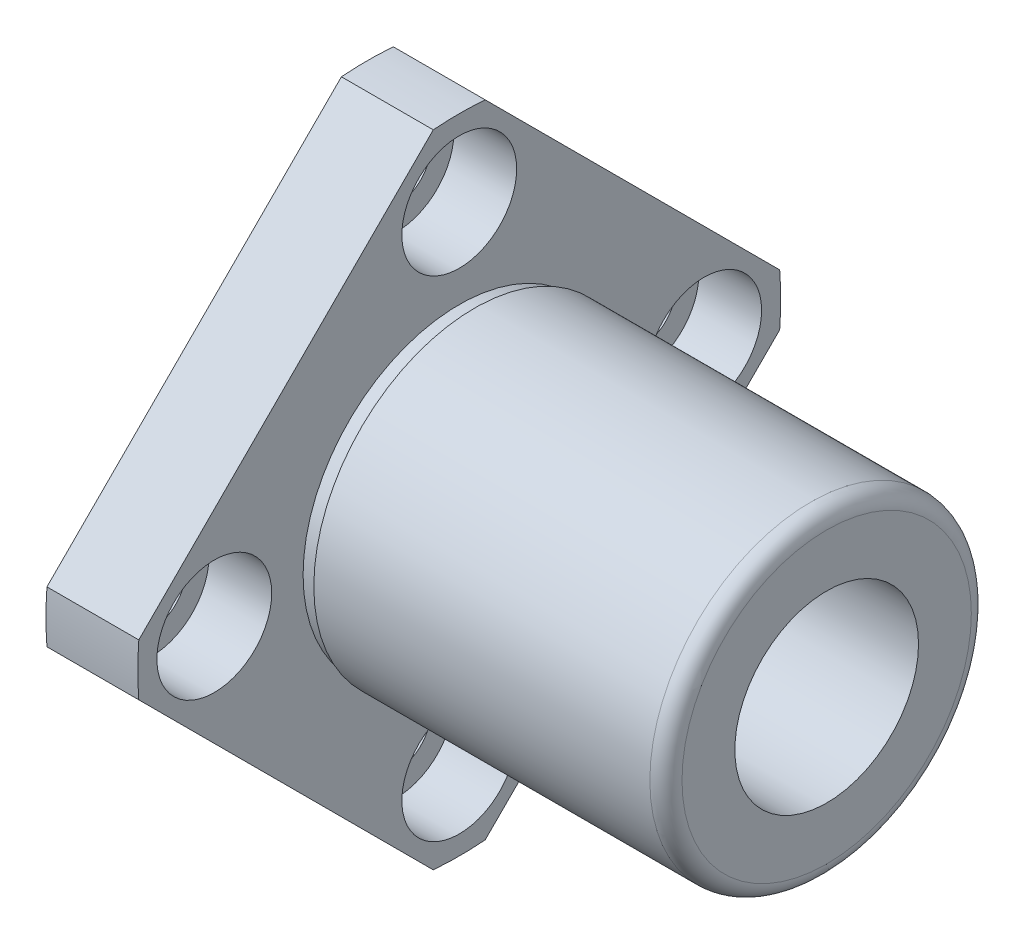
from build123d import *

# Parameters (mm, degrees)
BOSS_EXTRUDE1_DEPTH                              = 6
CBORE_FOR_M4_HEX_HEAD_MACHINE_SCREW1_D           = 4.5
CBORE_FOR_M4_HEX_HEAD_MACHINE_SCREW1_DEPTH       = 6
CBORE_FOR_M4_HEX_HEAD_MACHINE_SCREW1_CBORE_D     = 7.5
CBORE_FOR_M4_HEX_HEAD_MACHINE_SCREW1_CBORE_DEPTH = 4.1
F_12_0_12_DIAMETER_HOLE1_D                       = 12
F_12_0_12_DIAMETER_HOLE1_DEPTH                   = 30


with BuildPart() as part:
    # Sketch1 → Boss-Extrude1 (new body)
    with BuildSketch(Plane(origin=(0, 0, 0), x_dir=(0, -1, 0), z_dir=(-1, 0, 0))):
        with BuildLine():
            Line((-1.696016468, 20.93140053), (-20.93140053, 1.696016468))
            ThreePointArc((-20.93140053, 1.696016468), (-21, 0), (-20.93140053, -1.696016468))
            Line((-20.93140053, -1.696016468), (-1.696016468, -20.93140053))
            ThreePointArc((-1.696016468, -20.93140053), (0, -21), (1.696016468, -20.93140053))
            Line((1.696016468, -20.93140053), (20.93140053, -1.696016468))
            ThreePointArc((20.93140053, -1.696016468), (21, 0), (20.93140053, 1.696016468))
            Line((20.93140053, 1.696016468), (1.696016468, 20.93140053))
            ThreePointArc((1.696016468, 20.93140053), (0, 21), (-1.696016468, 20.93140053))
        make_face()
    extrude(amount=-BOSS_EXTRUDE1_DEPTH)

    # Sketch2 → Revolve1 (revolve)
    with BuildSketch(Plane(origin=(0, 0, 0), x_dir=(-1, 0, 0), z_dir=(0, 0, -1))):
        with BuildLine():
            Line((-30, 9.45), (-30, 0))
            Line((-30, 0), (-6, 0))
            Line((-6, 0), (-6, 10.2))
            Line((-6, 10.2), (-7, 10.2))
            Line((-7, 10.2), (-7, 10.5))
            Line((-7, 10.5), (-28.95, 10.5))
            ThreePointArc((-28.95, 10.5), (-29.69246212, 10.19246212), (-30, 9.45))
        make_face()
    revolve(axis=Axis((30.00125, 0, 0), (-1, 0, 0)))

    # CBORE for M4 Hex Head Machine Screw1
    with Locations(Plane(origin=(6, 0, 0), x_dir=(0, 0, -1), z_dir=(1, 0, 0))):
        with Locations((0, -16), (16, 0), (-16, 0), (0, 16)):
            CounterBoreHole(CBORE_FOR_M4_HEX_HEAD_MACHINE_SCREW1_D / 2, CBORE_FOR_M4_HEX_HEAD_MACHINE_SCREW1_CBORE_D / 2, CBORE_FOR_M4_HEX_HEAD_MACHINE_SCREW1_CBORE_DEPTH, depth=CBORE_FOR_M4_HEX_HEAD_MACHINE_SCREW1_DEPTH)

    # Ø12.0 (12) Diameter Hole1
    with Locations(Plane(origin=(30, 0, 0), x_dir=(0, 0, -1), z_dir=(1, 0, 0))):
        with Locations((0, 0)):
            Hole(F_12_0_12_DIAMETER_HOLE1_D / 2, depth=F_12_0_12_DIAMETER_HOLE1_DEPTH)


solid = part.part
